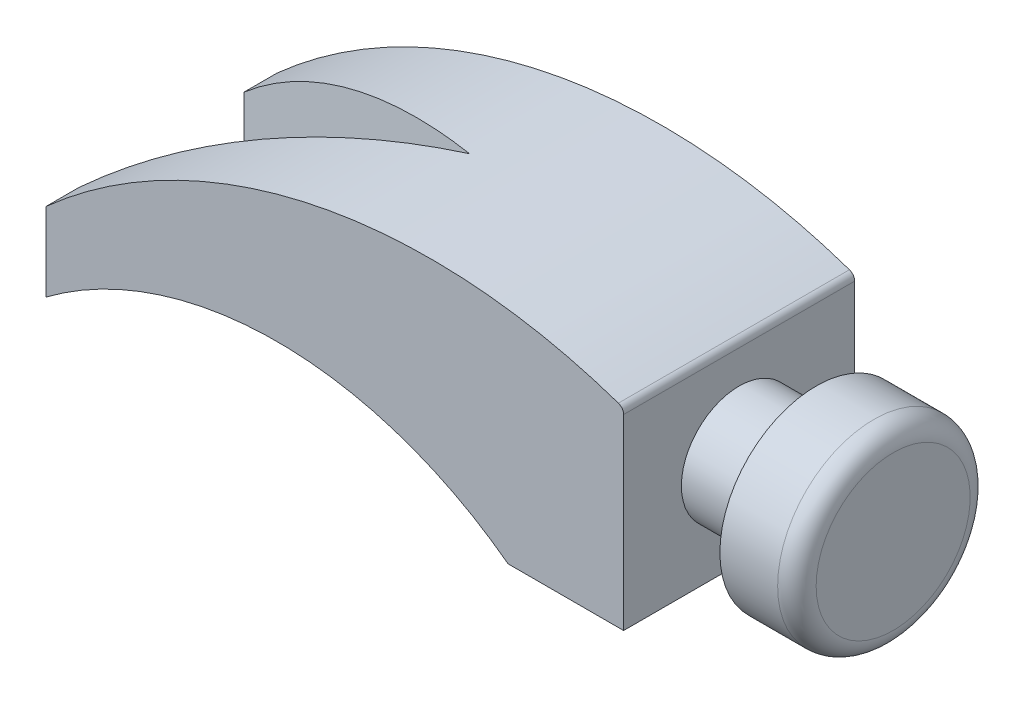
from build123d import *

# Parameters (mm, degrees)
Y_KSEKLIK_EKSTR_ZYON2_DEPTH = 30
KES_EKSTR_ZYON1_REACH       = 62
KES_EKSTR_ZYON2_REACH       = 62
RADYUS1_R                   = 2


with BuildPart() as part:
    # Çizim2 → Yükseklik-Ekstrüzyon2 (new body, symmetric)
    with BuildSketch(Plane(origin=(0, 0, 0), x_dir=(1, 0, 0), z_dir=(0, 1, 0))):
        Polygon((0, 30), (0, -30), (-150, -30), (-150, -21.435935394), (-70, 0), (-150, 21.435935394), (-150, 30), align=None)
    extrude(amount=Y_KSEKLIK_EKSTR_ZYON2_DEPTH, both=True)

    # Çizim3 → Kes-Ekstrüzyon1 (cut, up to next)
    with BuildSketch(Plane.XY.offset(30), mode=Mode.PRIVATE) as kes_ekstr_zyon1_sk1:
        with BuildLine():
            Line((-150, -30), (-30, -30))
            ThreePointArc((-30, -30), (-90, -10), (-150, -30))
        make_face()
    kes_ekstr_zyon1_tool1 = extrude(kes_ekstr_zyon1_sk1.sketch, amount=-KES_EKSTR_ZYON1_REACH, mode=Mode.PRIVATE) & part.part
    add(kes_ekstr_zyon1_tool1.solids().sort_by_distance((-90, -21.927203, 30))[0], mode=Mode.SUBTRACT)

    # Çizim5 → Döndür1 (revolve)
    with BuildSketch(Plane.XY):
        with BuildLine():
            Line((20, -30), (35, -30))
            ThreePointArc((35, -30), (38.535533906, -28.535533906), (40, -25))
            Line((40, -25), (40, -5))
            Line((40, -5), (0, -5))
            Line((0, -5), (0, -20))
            Line((0, -20), (20, -20))
            Line((20, -20), (20, -30))
        make_face()
    revolve(axis=Axis((0, -5, 0), (1, 0, 0)))

    # Çizim6 → Kes-Ekstrüzyon2 (cut, up to next)
    with BuildSketch(Plane.XY.offset(30), mode=Mode.PRIVATE) as kes_ekstr_zyon2_sk1:
        with BuildLine():
            Line((-150, -9.617957362), (-150, 30))
            Line((-150, 30), (0, 30))
            Line((0, 30), (0, 20))
            ThreePointArc((0, 20), (-79.056941504, 25.737381697), (-150, -9.617957362))
        make_face()
    kes_ekstr_zyon2_tool1 = extrude(kes_ekstr_zyon2_sk1.sketch, amount=-KES_EKSTR_ZYON2_REACH, mode=Mode.PRIVATE) & part.part
    add(kes_ekstr_zyon2_tool1.solids().sort_by_distance((-108.440185, 19.830355, 30))[0], mode=Mode.SUBTRACT)

    # Radyus1
    radyus1_edges = [part.edges().sort_by_distance(p)[0] for p in [
        (0, 20, 0),
    ]]
    fillet(radyus1_edges, radius=RADYUS1_R)


solid = part.part
